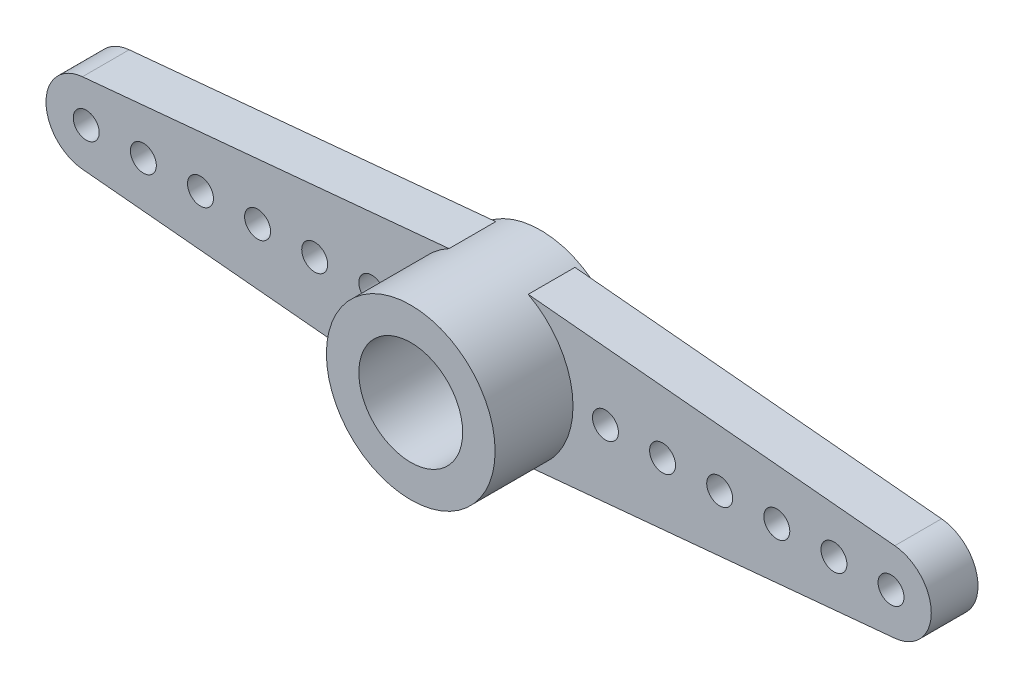
from build123d import *

# Parameters (mm, degrees)
BOSS_EXTRUDE1_DEPTH = 1.8
SKETCH2_R           = 3.25
SKETCH2_R_2         = 2.5
BOSS_EXTRUDE3_DEPTH = 0.2
SKETCH4_R           = 3.25
SKETCH4_R_2         = 2
BOSS_EXTRUDE4_DEPTH = 3
CUT_EXTRUDE1_REACH  = 4
SKETCH5_R           = 1.5
CUT_EXTRUDE2_REACH  = 6.8
SKETCH6_R           = 0.5


with BuildPart() as part:
    # Sketch1 → Boss-Extrude1 (new body)
    with BuildSketch(Plane.XY):
        with BuildLine():
            Line((1.525163579, 2.869908719), (15.645, 1.543202838))
            ThreePointArc((15.645, 1.543202838), (17.05, 0), (15.645, -1.543202838))
            Line((15.645, -1.543202838), (1.525163579, -2.869908719))
            ThreePointArc((1.525163579, -2.869908719), (0, -3.25), (-1.525163579, -2.869908719))
            Line((-1.525163579, -2.869908719), (-15.645, -1.543202838))
            ThreePointArc((-15.645, -1.543202838), (-17.05, 0), (-15.645, 1.543202838))
            Line((-15.645, 1.543202838), (-1.525163579, 2.869908719))
            ThreePointArc((-1.525163579, 2.869908719), (0, 3.25), (1.525163579, 2.869908719))
        make_face()
    extrude(amount=BOSS_EXTRUDE1_DEPTH)

    # Sketch2 → Boss-Extrude3 (add)
    with BuildSketch(Plane(origin=(0, 0, 0), x_dir=(-1, 0, 0), z_dir=(0, 0, -1))):
        Circle(SKETCH2_R)
        Circle(SKETCH2_R_2, mode=Mode.SUBTRACT)
    extrude(amount=BOSS_EXTRUDE3_DEPTH)

    # Sketch4 → Boss-Extrude4 (add)
    with BuildSketch(Plane.XY.offset(1.8)):
        Circle(SKETCH4_R)
        Circle(SKETCH4_R_2, mode=Mode.SUBTRACT)
    extrude(amount=BOSS_EXTRUDE4_DEPTH)

    # Sketch5 → Cut-Extrude1 (cut, up to next)
    with BuildSketch(Plane.XY.offset(1.8), mode=Mode.PRIVATE) as cut_extrude1_sk1:
        Circle(SKETCH5_R)
    cut_extrude1_tool1 = extrude(cut_extrude1_sk1.sketch, amount=-CUT_EXTRUDE1_REACH, mode=Mode.PRIVATE) & part.part
    add(cut_extrude1_tool1.solids().sort_by_distance((0, 0, 1.8))[0], mode=Mode.SUBTRACT)

    # Sketch6 → Cut-Extrude2 (cut, up to next)
    with BuildSketch(Plane(origin=(0, 0, 0), x_dir=(-1, 0, 0), z_dir=(0, 0, -1)), mode=Mode.PRIVATE) as cut_extrude2_sk1:
        with Locations((15.5, 0)):
            Circle(SKETCH6_R)
    cut_extrude2_tool1 = extrude(cut_extrude2_sk1.sketch, amount=-CUT_EXTRUDE2_REACH, mode=Mode.PRIVATE) & part.part
    add(cut_extrude2_tool1.solids().sort_by_distance((-15.5, 0, 0))[0], mode=Mode.SUBTRACT)
    # Sketch6 → Cut-Extrude2 (cut, up to next)
    with BuildSketch(Plane(origin=(0, 0, 0), x_dir=(-1, 0, 0), z_dir=(0, 0, -1)), mode=Mode.PRIVATE) as cut_extrude2_sk2:
        with Locations((13.3, 0)):
            Circle(SKETCH6_R)
    cut_extrude2_tool2 = extrude(cut_extrude2_sk2.sketch, amount=-CUT_EXTRUDE2_REACH, mode=Mode.PRIVATE) & part.part
    add(cut_extrude2_tool2.solids().sort_by_distance((-13.3, 0, 0))[0], mode=Mode.SUBTRACT)
    # Sketch6 → Cut-Extrude2 (cut, up to next)
    with BuildSketch(Plane(origin=(0, 0, 0), x_dir=(-1, 0, 0), z_dir=(0, 0, -1)), mode=Mode.PRIVATE) as cut_extrude2_sk3:
        with Locations((11.1, 0)):
            Circle(SKETCH6_R)
    cut_extrude2_tool3 = extrude(cut_extrude2_sk3.sketch, amount=-CUT_EXTRUDE2_REACH, mode=Mode.PRIVATE) & part.part
    add(cut_extrude2_tool3.solids().sort_by_distance((-11.1, 0, 0))[0], mode=Mode.SUBTRACT)
    # Sketch6 → Cut-Extrude2 (cut, up to next)
    with BuildSketch(Plane(origin=(0, 0, 0), x_dir=(-1, 0, 0), z_dir=(0, 0, -1)), mode=Mode.PRIVATE) as cut_extrude2_sk4:
        with Locations((8.9, 0)):
            Circle(SKETCH6_R)
    cut_extrude2_tool4 = extrude(cut_extrude2_sk4.sketch, amount=-CUT_EXTRUDE2_REACH, mode=Mode.PRIVATE) & part.part
    add(cut_extrude2_tool4.solids().sort_by_distance((-8.9, 0, 0))[0], mode=Mode.SUBTRACT)
    # Sketch6 → Cut-Extrude2 (cut, up to next)
    with BuildSketch(Plane(origin=(0, 0, 0), x_dir=(-1, 0, 0), z_dir=(0, 0, -1)), mode=Mode.PRIVATE) as cut_extrude2_sk5:
        with Locations((6.7, 0)):
            Circle(SKETCH6_R)
    cut_extrude2_tool5 = extrude(cut_extrude2_sk5.sketch, amount=-CUT_EXTRUDE2_REACH, mode=Mode.PRIVATE) & part.part
    add(cut_extrude2_tool5.solids().sort_by_distance((-6.7, 0, 0))[0], mode=Mode.SUBTRACT)
    # Sketch6 → Cut-Extrude2 (cut, up to next)
    with BuildSketch(Plane(origin=(0, 0, 0), x_dir=(-1, 0, 0), z_dir=(0, 0, -1)), mode=Mode.PRIVATE) as cut_extrude2_sk6:
        with Locations((4.5, 0)):
            Circle(SKETCH6_R)
    cut_extrude2_tool6 = extrude(cut_extrude2_sk6.sketch, amount=-CUT_EXTRUDE2_REACH, mode=Mode.PRIVATE) & part.part
    add(cut_extrude2_tool6.solids().sort_by_distance((-4.5, 0, 0))[0], mode=Mode.SUBTRACT)
    # Sketch6 → Cut-Extrude2 (cut, up to next)
    with BuildSketch(Plane(origin=(0, 0, 0), x_dir=(-1, 0, 0), z_dir=(0, 0, -1)), mode=Mode.PRIVATE) as cut_extrude2_sk7:
        with Locations((-4.5, 0)):
            Circle(SKETCH6_R)
    cut_extrude2_tool7 = extrude(cut_extrude2_sk7.sketch, amount=-CUT_EXTRUDE2_REACH, mode=Mode.PRIVATE) & part.part
    add(cut_extrude2_tool7.solids().sort_by_distance((4.5, 0, 0))[0], mode=Mode.SUBTRACT)
    # Sketch6 → Cut-Extrude2 (cut, up to next)
    with BuildSketch(Plane(origin=(0, 0, 0), x_dir=(-1, 0, 0), z_dir=(0, 0, -1)), mode=Mode.PRIVATE) as cut_extrude2_sk8:
        with Locations((-6.7, 0)):
            Circle(SKETCH6_R)
    cut_extrude2_tool8 = extrude(cut_extrude2_sk8.sketch, amount=-CUT_EXTRUDE2_REACH, mode=Mode.PRIVATE) & part.part
    add(cut_extrude2_tool8.solids().sort_by_distance((6.7, 0, 0))[0], mode=Mode.SUBTRACT)
    # Sketch6 → Cut-Extrude2 (cut, up to next)
    with BuildSketch(Plane(origin=(0, 0, 0), x_dir=(-1, 0, 0), z_dir=(0, 0, -1)), mode=Mode.PRIVATE) as cut_extrude2_sk9:
        with Locations((-8.9, 0)):
            Circle(SKETCH6_R)
    cut_extrude2_tool9 = extrude(cut_extrude2_sk9.sketch, amount=-CUT_EXTRUDE2_REACH, mode=Mode.PRIVATE) & part.part
    add(cut_extrude2_tool9.solids().sort_by_distance((8.9, 0, 0))[0], mode=Mode.SUBTRACT)
    # Sketch6 → Cut-Extrude2 (cut, up to next)
    with BuildSketch(Plane(origin=(0, 0, 0), x_dir=(-1, 0, 0), z_dir=(0, 0, -1)), mode=Mode.PRIVATE) as cut_extrude2_sk10:
        with Locations((-11.1, 0)):
            Circle(SKETCH6_R)
    cut_extrude2_tool10 = extrude(cut_extrude2_sk10.sketch, amount=-CUT_EXTRUDE2_REACH, mode=Mode.PRIVATE) & part.part
    add(cut_extrude2_tool10.solids().sort_by_distance((11.1, 0, 0))[0], mode=Mode.SUBTRACT)
    # Sketch6 → Cut-Extrude2 (cut, up to next)
    with BuildSketch(Plane(origin=(0, 0, 0), x_dir=(-1, 0, 0), z_dir=(0, 0, -1)), mode=Mode.PRIVATE) as cut_extrude2_sk11:
        with Locations((-13.3, 0)):
            Circle(SKETCH6_R)
    cut_extrude2_tool11 = extrude(cut_extrude2_sk11.sketch, amount=-CUT_EXTRUDE2_REACH, mode=Mode.PRIVATE) & part.part
    add(cut_extrude2_tool11.solids().sort_by_distance((13.3, 0, 0))[0], mode=Mode.SUBTRACT)
    # Sketch6 → Cut-Extrude2 (cut, up to next)
    with BuildSketch(Plane(origin=(0, 0, 0), x_dir=(-1, 0, 0), z_dir=(0, 0, -1)), mode=Mode.PRIVATE) as cut_extrude2_sk12:
        with Locations((-15.5, 0)):
            Circle(SKETCH6_R)
    cut_extrude2_tool12 = extrude(cut_extrude2_sk12.sketch, amount=-CUT_EXTRUDE2_REACH, mode=Mode.PRIVATE) & part.part
    add(cut_extrude2_tool12.solids().sort_by_distance((15.5, 0, 0))[0], mode=Mode.SUBTRACT)


solid = part.part
